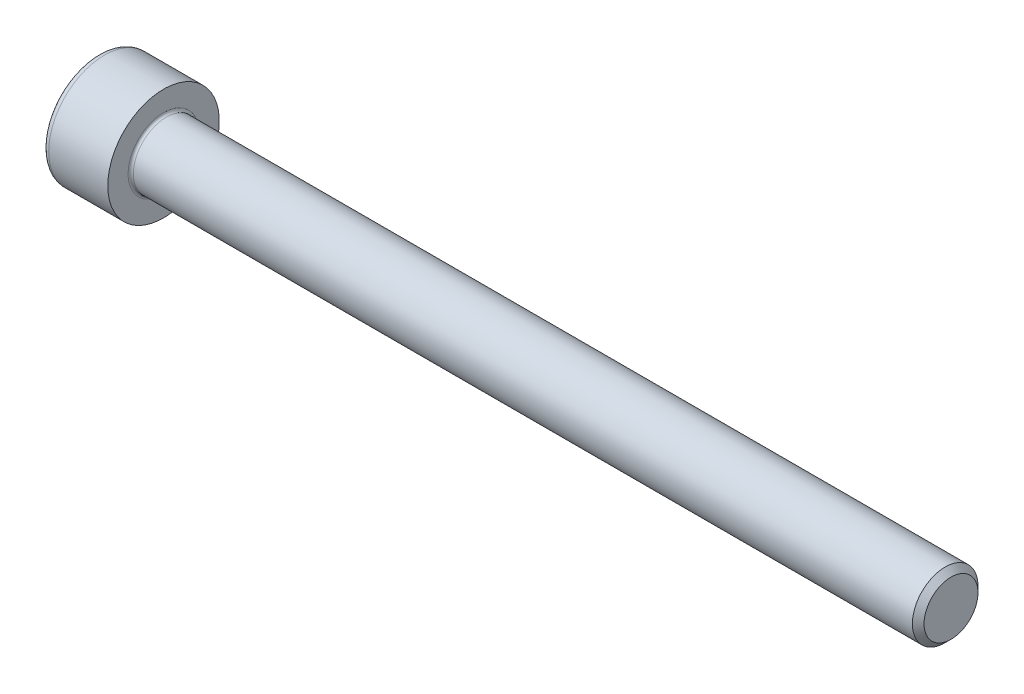
from build123d import *

# Parameters (mm, degrees)
FILLET1_R   = 0.2
FILLET2_R   = 0.5
HEX_2_DEPTH = 2.5


with BuildPart() as part:
    # BodySke → Base-Revolve (revolve)
    with BuildSketch(Plane.XY):
        Polygon((0, 0), (0, 4.25), (5, 4.25), (5, 2.5), (64.555, 2.5), (65, 2.055), (65, 0), align=None)
    revolve(axis=Axis((-31.75, 0, 0), (1, 0, 0)))

    # Fillet1
    fillet1_edges = [part.edges().sort_by_distance(p)[0] for p in [
        (5, -2.5, 0),
    ]]
    fillet(fillet1_edges, radius=FILLET1_R)

    # Fillet2
    fillet2_edges = [part.edges().sort_by_distance(p)[0] for p in [
        (0, -4.25, 0),
    ]]
    fillet(fillet2_edges, radius=FILLET2_R)

    # Sketch2 → Hex-PreBroach (revolve, cut)
    with BuildSketch(Plane.XY):
        Polygon((0, 2.01), (2.5, 2.01), (3.660474041, 0), (0, 0), align=None)
    revolve(axis=Axis((0, 0, 0), (1, 0, 0)), mode=Mode.SUBTRACT)

    # Sketch3 → Hex 2 (cut)
    with BuildSketch(Plane(origin=(0, 0, 0), x_dir=(0, 0.5, 0.866025404), z_dir=(-1, 0, 0))):
        Polygon((1.160474041, 2.01), (-1.160474041, 2.01), (-2.320948082, 0), (-1.160474041, -2.01), (1.160474041, -2.01), (2.320948082, 0), align=None)
    extrude(amount=-HEX_2_DEPTH, mode=Mode.SUBTRACT)


solid = part.part
